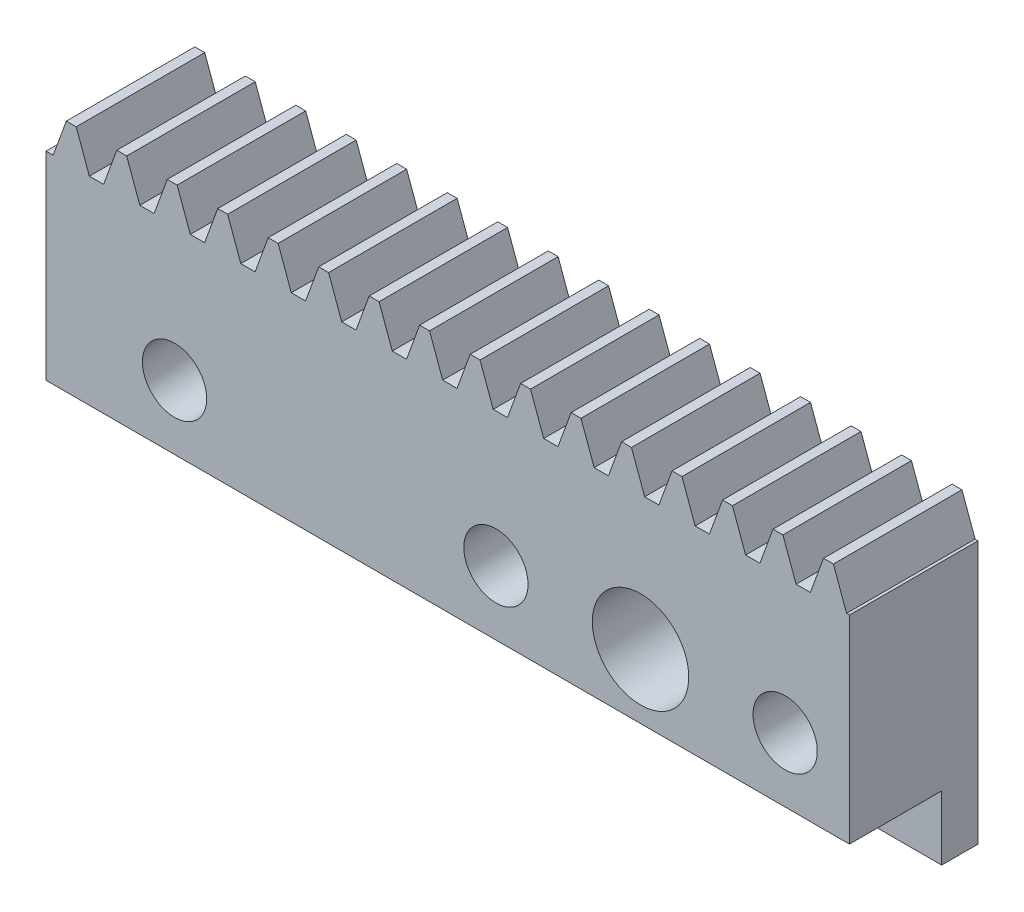
from build123d import *

# Parameters (mm, degrees)
BLANKSKE_W          = 25
BLANKSKE_H          = 7.3
BLANK_DEPTH         = 4
TOOTHCUTSIM_DEPTH   = 27.349383294
TEETHCUTS_COUNT     = 17
TEETHCUTS_PITCH     = 1.570796325
CUT_EXTRUDE1_DEPTH  = 27.349383294
SKETCH4_W           = 25
SKETCH4_H           = 1.13
BOSS_EXTRUDE1_DEPTH = 2


with BuildPart() as part:
    # BlankSke → Blank (new body)
    with BuildSketch(Plane.XY):
        with Locations((12.5, 3.65)):
            Rectangle(BLANKSKE_W, BLANKSKE_H)
    extrude(amount=-BLANK_DEPTH)

    # TooCutSkeSim → ToothCutSim (cut, through all)
    with BuildSketch(Plane.XY):
        Polygon((0.222217685, 6.175), (-0.222217685, 6.175), (-0.640929042, 7.3254), (0.640929042, 7.3254), align=None)
    toothcutsim = extrude(amount=-TOOTHCUTSIM_DEPTH, mode=Mode.SUBTRACT)

    # TeethCuts: ToothCutSim ×17
    with Locations(*[(i * TEETHCUTS_PITCH, 0, 0) for i in range(1, TEETHCUTS_COUNT)]):
        add(toothcutsim, mode=Mode.SUBTRACT)

    # Sketch1 → Cut-Extrude1 (cut, through all)
    with BuildSketch(Plane(origin=(0, 0, -4), x_dir=(-1, 0, 0), z_dir=(0, 0, -1))):
        with BuildLine():
            Line((-23, 1), (-23, 2))
            Line((-23, 2), (-24, 2))
            ThreePointArc((-24, 2), (-23.707106781, 1.292893219), (-23, 1))
        make_face()
        with BuildLine():
            Line((-24, 2), (-23, 2))
            Line((-23, 2), (-23, 3))
            ThreePointArc((-23, 3), (-23.707106781, 2.707106781), (-24, 2))
        make_face()
        with BuildLine():
            Line((-23, 3), (-23, 2))
            Line((-23, 2), (-23, 1))
            ThreePointArc((-23, 1), (-22.292893219, 1.292893219), (-22, 2))
            ThreePointArc((-22, 2), (-22.292893219, 2.707106781), (-23, 3))
        make_face()
        with BuildLine():
            ThreePointArc((-17, 2), (-18.5, 3.5), (-20, 2))
            Line((-20, 2), (-17, 2))
        make_face()
        with BuildLine():
            Line((-17, 2), (-20, 2))
            ThreePointArc((-20, 2), (-18.5, 0.5), (-17, 2))
        make_face()
        with BuildLine():
            ThreePointArc((-13, 2), (-14, 3), (-15, 2))
            Line((-15, 2), (-13, 2))
        make_face()
        with BuildLine():
            Line((-13, 2), (-15, 2))
            ThreePointArc((-15, 2), (-14, 1), (-13, 2))
        make_face()
        with BuildLine():
            ThreePointArc((-3, 2), (-4, 3), (-5, 2))
            Line((-5, 2), (-3, 2))
        make_face()
        with BuildLine():
            Line((-3, 2), (-5, 2))
            ThreePointArc((-5, 2), (-4, 1), (-3, 2))
        make_face()
    extrude(amount=-CUT_EXTRUDE1_DEPTH, mode=Mode.SUBTRACT)

    # Sketch4 → Boss-Extrude1 (add)
    with BuildSketch(Plane.XZ):
        with Locations((12.5, -3.435)):
            Rectangle(SKETCH4_W, SKETCH4_H)
    extrude(amount=BOSS_EXTRUDE1_DEPTH)


solid = part.part
